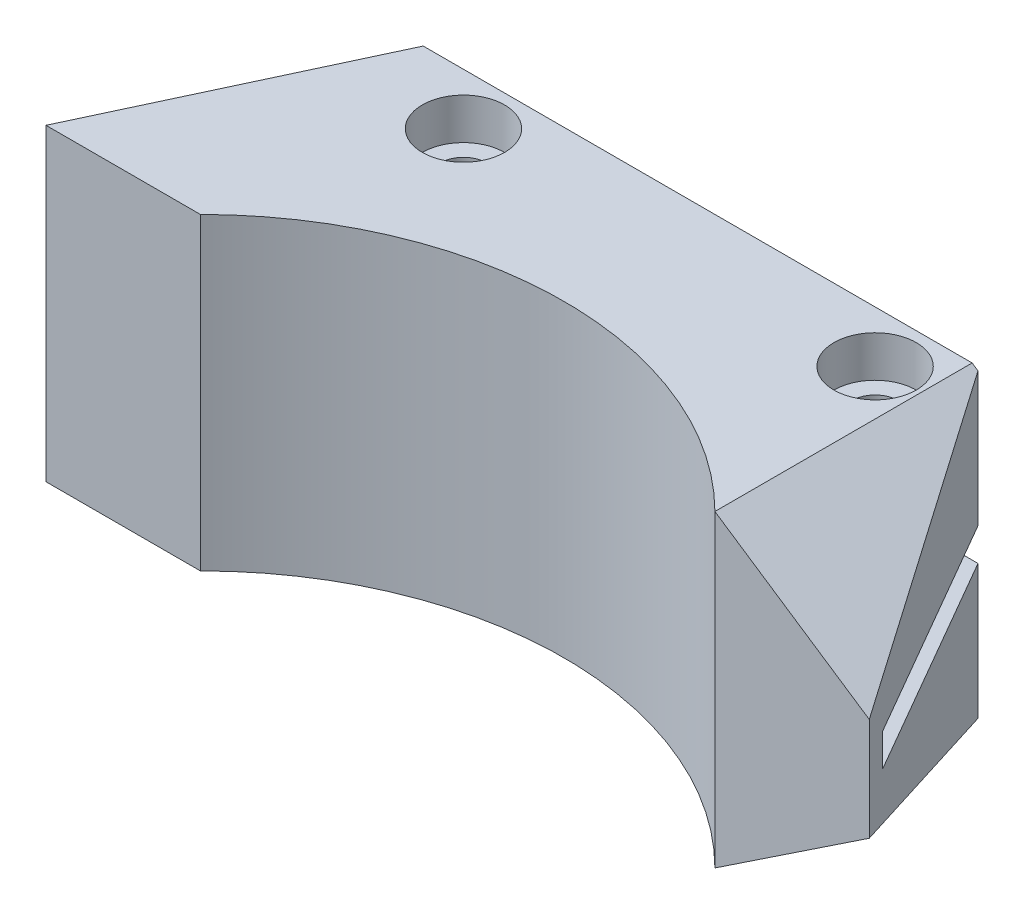
from build123d import *

# Parameters (mm, degrees)
BOSS_EXTRUDE1_DEPTH            = 15
CUT_EXTRUDE1_DEPTH             = 1.5875
CUT_EXTRUDE1_DEPTH_BACK        = 1.5875
CBORE_FOR_M4_SHCS1_D           = 4.5
CBORE_FOR_M4_SHCS1_CBORE_D     = 8
CBORE_FOR_M4_SHCS1_CBORE_DEPTH = 4
CUT_EXTRUDE2_DEPTH             = 26


with BuildPart() as part:
    # Sketch1 → Boss-Extrude1 (new body, symmetric)
    with BuildSketch(Plane(origin=(0, 0, 0), x_dir=(1, 0, 0), z_dir=(0, 1, 0))):
        with BuildLine():
            Line((0, 0), (-15, 0))
            ThreePointArc((-15, 0), (-40, 10.355339059), (-65, 0))
            Line((-65, 0), (-80, 0))
            Line((-80, 0), (-68.342308546, 25))
            Line((-68.342308546, 25), (-14.43375673, 25))
            Line((-14.43375673, 25), (0, 0))
        make_face()
    extrude(amount=BOSS_EXTRUDE1_DEPTH, both=True)

    # Sketch2 → Cut-Extrude1 (cut, two sides)
    with BuildSketch(Plane(origin=(0, 0, 0), x_dir=(1, 0, 0), z_dir=(0, 1, 0))) as cut_extrude1_sk:
        with BuildLine():
            Line((-13.279056191, 3), (-1.732050808, 3))
            Line((-1.732050808, 3), (-14.43375673, 25))
            Line((-14.43375673, 25), (-68.342308546, 25))
            Line((-68.342308546, 25), (-73.005385128, 15))
            Line((-73.005385128, 15), (-22.040346526, 15))
            ThreePointArc((-22.040346526, 15), (-20.452846526, 14.574630657), (-19.290715869, 13.4125))
            Line((-19.290715869, 13.4125), (-13.279056191, 3))
        make_face()
    extrude(amount=CUT_EXTRUDE1_DEPTH, mode=Mode.SUBTRACT)
    extrude(cut_extrude1_sk.sketch, amount=-CUT_EXTRUDE1_DEPTH_BACK, mode=Mode.SUBTRACT)

    # CBORE for M4 SHCS1 (through all)
    with Locations(Plane(origin=(0, 15, 0), x_dir=(1, 0, 0), z_dir=(0, 1, 0))):
        with Locations((-59.43375673, 20), (-19.43375673, 20)):
            CounterBoreHole(CBORE_FOR_M4_SHCS1_D / 2, CBORE_FOR_M4_SHCS1_CBORE_D / 2, CBORE_FOR_M4_SHCS1_CBORE_DEPTH)

    # Sketch7 → Cut-Extrude2 (cut, through all)
    with BuildSketch(Plane.XY):
        Polygon((0, 5), (-15, 15), (0, 15), align=None)
        Polygon((0, -15), (-15, -15), (0, -5), align=None)
    extrude(amount=-CUT_EXTRUDE2_DEPTH, mode=Mode.SUBTRACT)


solid = part.part
